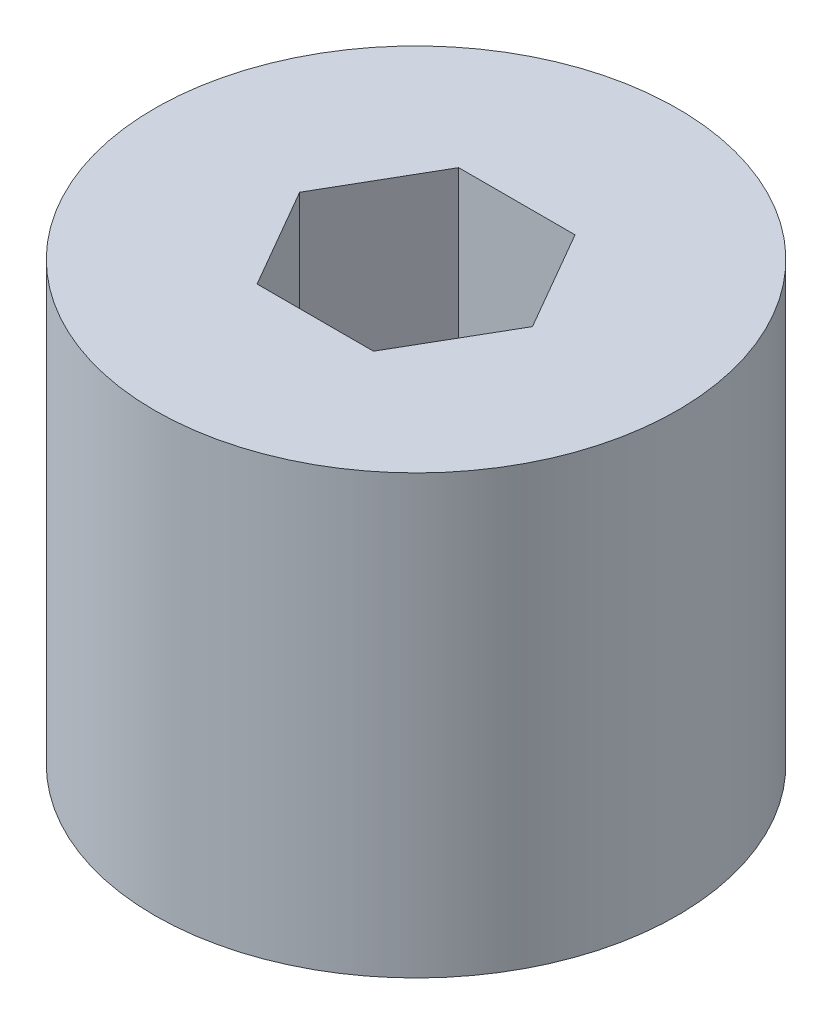
from build123d import *

# Parameters (mm, degrees)
SKETCH1_R           = 17.4625
BOSS_EXTRUDE1_DEPTH = 29.21


with BuildPart() as part:
    # Sketch1 → Boss-Extrude1 (new body)
    with BuildSketch(Plane(origin=(0, 0, 0), x_dir=(1, 0, 0), z_dir=(0, 1, 0))):
        Circle(SKETCH1_R)
        Polygon((7.772289324, 0), (3.886144662, 6.731), (-3.886144662, 6.731), (-7.772289324, 0), (-3.886144662, -6.731), (3.886144662, -6.731), align=None, mode=Mode.SUBTRACT)
    extrude(amount=BOSS_EXTRUDE1_DEPTH)


solid = part.part
